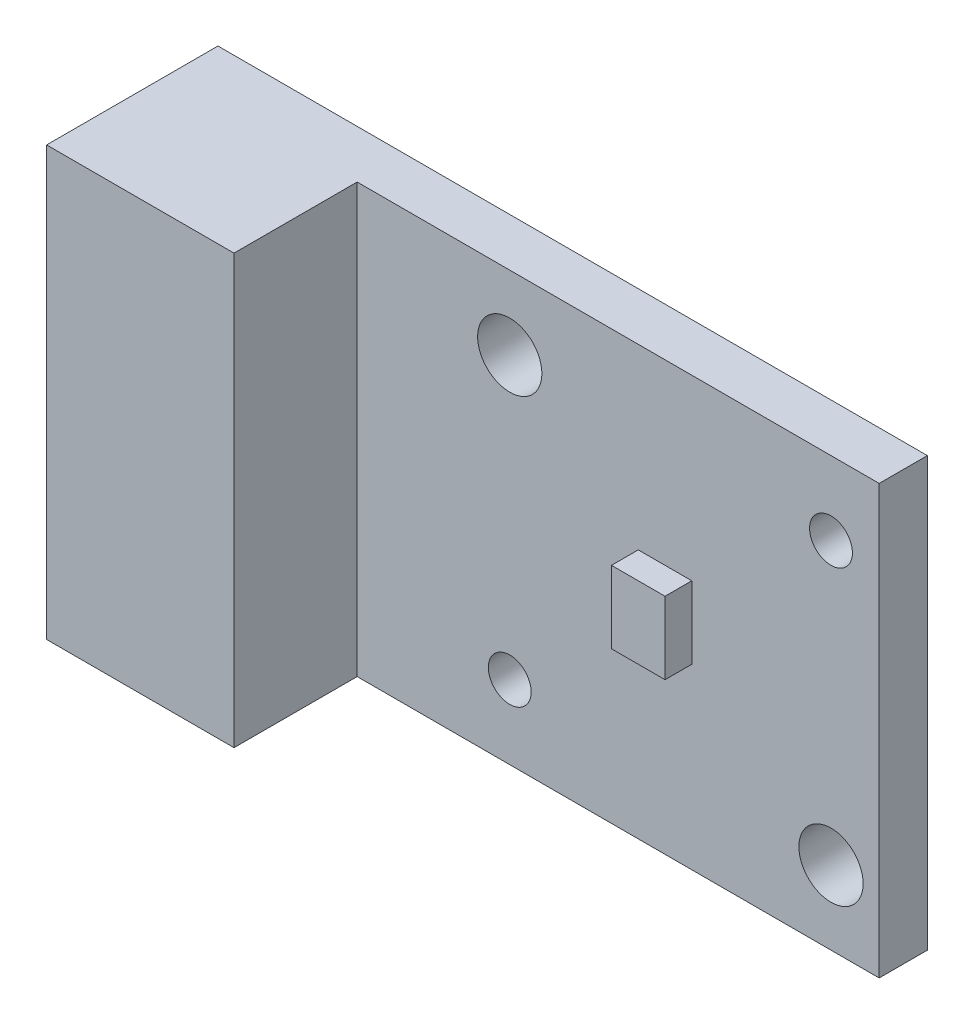
from build123d import *

# Parameters (mm, degrees)
SKETCH2_W           = 26.5
SKETCH2_H           = 16
BOSS_EXTRUDE1_DEPTH = 1.8
SKETCH3_W           = 7
SKETCH3_H           = 16
BOSS_EXTRUDE2_DEPTH = 4.6
SKETCH4_W           = 2
SKETCH4_H           = 2.7
BOSS_EXTRUDE3_DEPTH = 1
SKETCH5_R           = 0.8
SKETCH5_R_2         = 1.2
CUT_EXTRUDE1_DEPTH  = 2.8


with BuildPart() as part:
    # Sketch2 → Boss-Extrude1 (new body)
    with BuildSketch(Plane.XY):
        with Locations((13.25, 8)):
            Rectangle(SKETCH2_W, SKETCH2_H)
    extrude(amount=BOSS_EXTRUDE1_DEPTH)

    # Sketch3 → Boss-Extrude2 (add)
    with BuildSketch(Plane.XY.offset(1.8)):
        with Locations((3.5, 8)):
            Rectangle(SKETCH3_W, SKETCH3_H)
    extrude(amount=BOSS_EXTRUDE2_DEPTH)

    # Sketch4 → Boss-Extrude3 (add)
    with BuildSketch(Plane.XY.offset(1.8)):
        with Locations((18.5, 8)):
            Rectangle(SKETCH4_W, SKETCH4_H)
    extrude(amount=BOSS_EXTRUDE3_DEPTH)

    # Sketch5 → Cut-Extrude1 (cut, through all)
    with BuildSketch(Plane.XY.offset(1.8)):
        with Locations((24.7, 13.25)):
            Circle(SKETCH5_R)
        with Locations((12.7, 2.75)):
            Circle(SKETCH5_R)
        with Locations((24.7, 2.75)):
            Circle(SKETCH5_R_2)
        with Locations((12.7, 13.25)):
            Circle(SKETCH5_R_2)
    extrude(amount=-CUT_EXTRUDE1_DEPTH, mode=Mode.SUBTRACT)


solid = part.part
